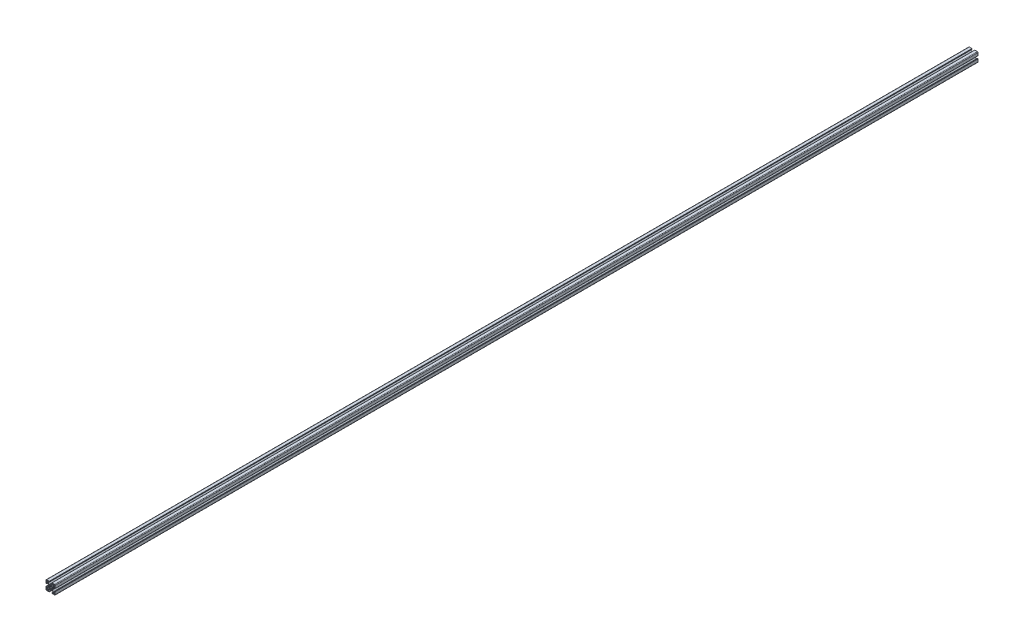
from build123d import *

# Parameters (mm, degrees)
EXTRUDE1_DEPTH = 3000


with BuildPart() as part:
    # Sketch1 → Extrude1 (new body)
    with BuildSketch(Plane.XY):
        with BuildLine():
            Line((12.74247465, -4.5), (12.74247465, -7.732519321))
            ThreePointArc((12.74247465, -7.732519321), (12.602449697, -8.097296796), (12.242781236, -8.249967))
            Line((12.242781236, -8.249967), (10.260188032, -8.249967))
            ThreePointArc((10.260188032, -8.249967), (10.068847082, -8.211906919), (9.906636056, -8.103520976))
            Line((9.906636056, -8.103520976), (5.981117769, -4.178002689))
            ThreePointArc((5.981117769, -4.178002689), (5.872731827, -4.015791664), (5.834671745, -3.824450713))
            Line((5.834671745, -3.824450713), (5.834671745, -1.01249595))
            Line((5.834671745, -1.01249595), (5.324673785, -0.06249975))
            Line((5.324673785, -0.06249975), (5.834671745, 0.88749645))
            Line((5.834671745, 0.88749645), (5.834671745, 3.824450713))
            ThreePointArc((5.834671745, 3.824450713), (5.872731827, 4.015791664), (5.981117769, 4.178002689))
            Line((5.981117769, 4.178002689), (9.906636056, 8.103520976))
            ThreePointArc((9.906636056, 8.103520976), (10.068847082, 8.211906919), (10.260188032, 8.249967))
            Line((10.260188032, 8.249967), (12.242781236, 8.249967))
            ThreePointArc((12.242781236, 8.249967), (12.602449697, 8.097296796), (12.74247465, 7.732519321))
            Line((12.74247465, 7.732519321), (12.74247465, 4.5))
            ThreePointArc((12.74247465, 4.5), (12.88892126, 4.146446609), (13.24247465, 4))
            Line((13.24247465, 4), (14.49994, 4))
            ThreePointArc((14.49994, 4), (14.853493391, 4.146446609), (14.99994, 4.5))
            Line((14.99994, 4.5), (14.99994, 12.999948))
            ThreePointArc((14.99994, 12.999948), (14.414155906, 14.414155906), (12.999948, 14.99994))
            Line((12.999948, 14.99994), (4.5, 14.99994))
            ThreePointArc((4.5, 14.99994), (4.146446609, 14.853493391), (4, 14.49994))
            Line((4, 14.49994), (4, 13.24247465))
            ThreePointArc((4, 13.24247465), (4.146446609, 12.88892126), (4.5, 12.74247465))
            Line((4.5, 12.74247465), (7.732519321, 12.74247465))
            ThreePointArc((7.732519321, 12.74247465), (8.097296796, 12.602449697), (8.249967, 12.242781236))
            Line((8.249967, 12.242781236), (8.249967, 10.260188032))
            ThreePointArc((8.249967, 10.260188032), (8.211906919, 10.068847082), (8.103520976, 9.906636056))
            Line((8.103520976, 9.906636056), (4.178002689, 5.981117769))
            ThreePointArc((4.178002689, 5.981117769), (4.015791664, 5.872731827), (3.824450713, 5.834671745))
            Line((3.824450713, 5.834671745), (0.9499962, 5.834671745))
            Line((0.9499962, 5.834671745), (0, 5.324673785))
            Line((0, 5.324673785), (-0.9499962, 5.834671745))
            Line((-0.9499962, 5.834671745), (-3.824450713, 5.834671745))
            ThreePointArc((-3.824450713, 5.834671745), (-4.015791664, 5.872731827), (-4.178002689, 5.981117769))
            Line((-4.178002689, 5.981117769), (-8.103520976, 9.906636056))
            ThreePointArc((-8.103520976, 9.906636056), (-8.211906919, 10.068847082), (-8.249967, 10.260188032))
            Line((-8.249967, 10.260188032), (-8.249967, 12.242781236))
            ThreePointArc((-8.249967, 12.242781236), (-8.097296796, 12.602449697), (-7.732519321, 12.74247465))
            Line((-7.732519321, 12.74247465), (-4.5, 12.74247465))
            ThreePointArc((-4.5, 12.74247465), (-4.146446609, 12.88892126), (-4, 13.24247465))
            Line((-4, 13.24247465), (-4, 14.49994))
            ThreePointArc((-4, 14.49994), (-4.146446609, 14.853493391), (-4.5, 14.99994))
            Line((-4.5, 14.99994), (-12.999948, 14.99994))
            ThreePointArc((-12.999948, 14.99994), (-14.414155906, 14.414155906), (-14.99994, 12.999948))
            Line((-14.99994, 12.999948), (-14.99994, 4.5))
            ThreePointArc((-14.99994, 4.5), (-14.853493391, 4.146446609), (-14.49994, 4))
            Line((-14.49994, 4), (-13.24247465, 4))
            ThreePointArc((-13.24247465, 4), (-12.88892126, 4.146446609), (-12.74247465, 4.5))
            Line((-12.74247465, 4.5), (-12.74247465, 7.732519321))
            ThreePointArc((-12.74247465, 7.732519321), (-12.602449697, 8.097296796), (-12.242781236, 8.249967))
            Line((-12.242781236, 8.249967), (-10.260188032, 8.249967))
            ThreePointArc((-10.260188032, 8.249967), (-10.068847082, 8.211906919), (-9.906636056, 8.103520976))
            Line((-9.906636056, 8.103520976), (-5.981117769, 4.178002689))
            ThreePointArc((-5.981117769, 4.178002689), (-5.872731827, 4.015791664), (-5.834671745, 3.824450713))
            Line((-5.834671745, 3.824450713), (-5.834671745, 0.88749645))
            Line((-5.834671745, 0.88749645), (-5.324673785, -0.06249975))
            Line((-5.324673785, -0.06249975), (-5.834671745, -1.01249595))
            Line((-5.834671745, -1.01249595), (-5.834671745, -3.824450713))
            ThreePointArc((-5.834671745, -3.824450713), (-5.872731827, -4.015791664), (-5.981117769, -4.178002689))
            Line((-5.981117769, -4.178002689), (-9.906636056, -8.103520976))
            ThreePointArc((-9.906636056, -8.103520976), (-10.068847082, -8.211906919), (-10.260188032, -8.249967))
            Line((-10.260188032, -8.249967), (-12.242781236, -8.249967))
            ThreePointArc((-12.242781236, -8.249967), (-12.602449697, -8.097296796), (-12.74247465, -7.732519321))
            Line((-12.74247465, -7.732519321), (-12.74247465, -4.5))
            ThreePointArc((-12.74247465, -4.5), (-12.88892126, -4.146446609), (-13.24247465, -4))
            Line((-13.24247465, -4), (-14.49994, -4))
            ThreePointArc((-14.49994, -4), (-14.853493391, -4.146446609), (-14.99994, -4.5))
            Line((-14.99994, -4.5), (-14.99994, -12.999948))
            ThreePointArc((-14.99994, -12.999948), (-14.414155906, -14.414155906), (-12.999948, -14.99994))
            Line((-12.999948, -14.99994), (-4.5, -14.99994))
            ThreePointArc((-4.5, -14.99994), (-4.146446609, -14.853493391), (-4, -14.49994))
            Line((-4, -14.49994), (-4, -13.24247465))
            ThreePointArc((-4, -13.24247465), (-4.146446609, -12.88892126), (-4.5, -12.74247465))
            Line((-4.5, -12.74247465), (-7.732519321, -12.74247465))
            ThreePointArc((-7.732519321, -12.74247465), (-8.097296796, -12.602449697), (-8.249967, -12.242781236))
            Line((-8.249967, -12.242781236), (-8.249967, -10.260188032))
            ThreePointArc((-8.249967, -10.260188032), (-8.211906919, -10.068847082), (-8.103520976, -9.906636056))
            Line((-8.103520976, -9.906636056), (-4.178002689, -5.981117769))
            ThreePointArc((-4.178002689, -5.981117769), (-4.015791664, -5.872731827), (-3.824450713, -5.834671745))
            Line((-3.824450713, -5.834671745), (-0.9499962, -5.834671745))
            Line((-0.9499962, -5.834671745), (0, -5.324673785))
            Line((0, -5.324673785), (0.9499962, -5.834671745))
            Line((0.9499962, -5.834671745), (3.824450713, -5.834671745))
            ThreePointArc((3.824450713, -5.834671745), (4.015791664, -5.872731827), (4.178002689, -5.981117769))
            Line((4.178002689, -5.981117769), (8.103520976, -9.906636056))
            ThreePointArc((8.103520976, -9.906636056), (8.211906919, -10.068847082), (8.249967, -10.260188032))
            Line((8.249967, -10.260188032), (8.249967, -12.242781236))
            ThreePointArc((8.249967, -12.242781236), (8.097296796, -12.602449697), (7.732519321, -12.74247465))
            Line((7.732519321, -12.74247465), (4.5, -12.74247465))
            ThreePointArc((4.5, -12.74247465), (4.146446609, -12.88892126), (4, -13.24247465))
            Line((4, -13.24247465), (4, -14.49994))
            ThreePointArc((4, -14.49994), (4.146446609, -14.853493391), (4.5, -14.99994))
            Line((4.5, -14.99994), (12.999948, -14.99994))
            ThreePointArc((12.999948, -14.99994), (14.414155906, -14.414155906), (14.99994, -12.999948))
            Line((14.99994, -12.999948), (14.99994, -4.5))
            ThreePointArc((14.99994, -4.5), (14.853493391, -4.146446609), (14.49994, -4))
            Line((14.49994, -4), (13.24247465, -4))
            ThreePointArc((13.24247465, -4), (12.88892126, -4.146446609), (12.74247465, -4.5))
        make_face()
        with BuildLine():
            Line((9.499962, -13.318946724), (9.499962, -9.87996048))
            ThreePointArc((9.499962, -9.87996048), (9.611260978, -9.611260978), (9.87996048, -9.499962))
            Line((9.87996048, -9.499962), (13.318946724, -9.499962))
            ThreePointArc((13.318946724, -9.499962), (13.58835333, -9.61155387), (13.6999452, -9.880960476))
            Line((13.6999452, -9.880960476), (13.6999452, -12.6999492))
            ThreePointArc((13.6999452, -12.6999492), (13.407053153, -13.407053153), (12.6999492, -13.6999452))
            Line((12.6999492, -13.6999452), (9.880960476, -13.6999452))
            ThreePointArc((9.880960476, -13.6999452), (9.61155387, -13.58835333), (9.499962, -13.318946724))
        make_face(mode=Mode.SUBTRACT)
        with BuildLine():
            Line((-13.318946724, -9.499962), (-9.87996048, -9.499962))
            ThreePointArc((-9.87996048, -9.499962), (-9.611260978, -9.611260978), (-9.499962, -9.87996048))
            Line((-9.499962, -9.87996048), (-9.499962, -13.318946724))
            ThreePointArc((-9.499962, -13.318946724), (-9.61155387, -13.58835333), (-9.880960476, -13.6999452))
            Line((-9.880960476, -13.6999452), (-12.6999492, -13.6999452))
            ThreePointArc((-12.6999492, -13.6999452), (-13.407053153, -13.407053153), (-13.6999452, -12.6999492))
            Line((-13.6999452, -12.6999492), (-13.6999452, -9.880960476))
            ThreePointArc((-13.6999452, -9.880960476), (-13.58835333, -9.61155387), (-13.318946724, -9.499962))
        make_face(mode=Mode.SUBTRACT)
        with BuildLine():
            Line((-1.494225248, -3.198138712), (-2.473341823, -3.979927146))
            ThreePointArc((-2.473341823, -3.979927146), (-3.900227701, -3.900227701), (-3.979927146, -2.473341823))
            Line((-3.979927146, -2.473341823), (-3.198138712, -1.494225248))
            ThreePointArc((-3.198138712, -1.494225248), (-3.52998588, 0), (-3.198138712, 1.494225248))
            Line((-3.198138712, 1.494225248), (-3.979927146, 2.473341823))
            ThreePointArc((-3.979927146, 2.473341823), (-3.900227701, 3.900227701), (-2.473341823, 3.979927146))
            Line((-2.473341823, 3.979927146), (-1.494225248, 3.198138712))
            ThreePointArc((-1.494225248, 3.198138712), (0, 3.52998588), (1.494225248, 3.198138712))
            Line((1.494225248, 3.198138712), (2.473341823, 3.979927146))
            ThreePointArc((2.473341823, 3.979927146), (3.900227701, 3.900227701), (3.979927146, 2.473341823))
            Line((3.979927146, 2.473341823), (3.198138712, 1.494225248))
            ThreePointArc((3.198138712, 1.494225248), (3.52998588, 0), (3.198138712, -1.494225248))
            Line((3.198138712, -1.494225248), (3.979927146, -2.473341823))
            ThreePointArc((3.979927146, -2.473341823), (3.900227701, -3.900227701), (2.473341823, -3.979927146))
            Line((2.473341823, -3.979927146), (1.494225248, -3.198138712))
            ThreePointArc((1.494225248, -3.198138712), (0, -3.52998588), (-1.494225248, -3.198138712))
        make_face(mode=Mode.SUBTRACT)
        with BuildLine():
            Line((-9.499962, 13.318946724), (-9.499962, 9.87996048))
            ThreePointArc((-9.499962, 9.87996048), (-9.611260978, 9.611260978), (-9.87996048, 9.499962))
            Line((-9.87996048, 9.499962), (-13.318946724, 9.499962))
            ThreePointArc((-13.318946724, 9.499962), (-13.58835333, 9.61155387), (-13.6999452, 9.880960476))
            Line((-13.6999452, 9.880960476), (-13.6999452, 12.6999492))
            ThreePointArc((-13.6999452, 12.6999492), (-13.407053153, 13.407053153), (-12.6999492, 13.6999452))
            Line((-12.6999492, 13.6999452), (-9.880960476, 13.6999452))
            ThreePointArc((-9.880960476, 13.6999452), (-9.61155387, 13.58835333), (-9.499962, 13.318946724))
        make_face(mode=Mode.SUBTRACT)
        with BuildLine():
            Line((9.880960476, 13.6999452), (12.6999492, 13.6999452))
            ThreePointArc((12.6999492, 13.6999452), (13.407053153, 13.407053153), (13.6999452, 12.6999492))
            Line((13.6999452, 12.6999492), (13.6999452, 9.880960476))
            ThreePointArc((13.6999452, 9.880960476), (13.58835333, 9.61155387), (13.318946724, 9.499962))
            Line((13.318946724, 9.499962), (9.87996048, 9.499962))
            ThreePointArc((9.87996048, 9.499962), (9.611260978, 9.611260978), (9.499962, 9.87996048))
            Line((9.499962, 9.87996048), (9.499962, 13.318946724))
            ThreePointArc((9.499962, 13.318946724), (9.61155387, 13.58835333), (9.880960476, 13.6999452))
        make_face(mode=Mode.SUBTRACT)
    extrude(amount=-EXTRUDE1_DEPTH)


solid = part.part
